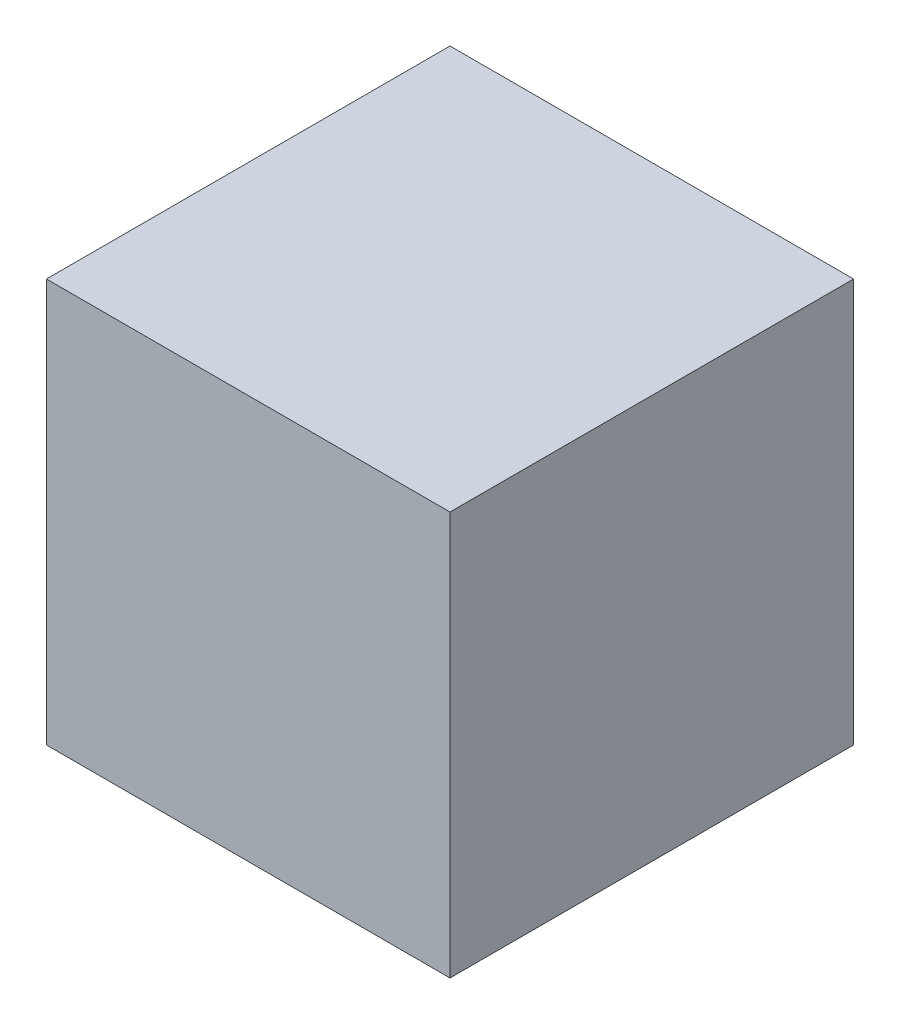
from build123d import *

# Parameters (mm, degrees)
SKETCH1_W           = 25
SKETCH1_H           = 25
BOSS_EXTRUDE1_DEPTH = 25


with BuildPart() as part:
    # Sketch1 → Boss-Extrude1 (new body)
    with BuildSketch(Plane(origin=(0, 0, 0), x_dir=(1, 0, 0), z_dir=(0, 1, 0))):
        with Locations((12.5, 12.5)):
            Rectangle(SKETCH1_W, SKETCH1_H)
    extrude(amount=BOSS_EXTRUDE1_DEPTH)


solid = part.part
